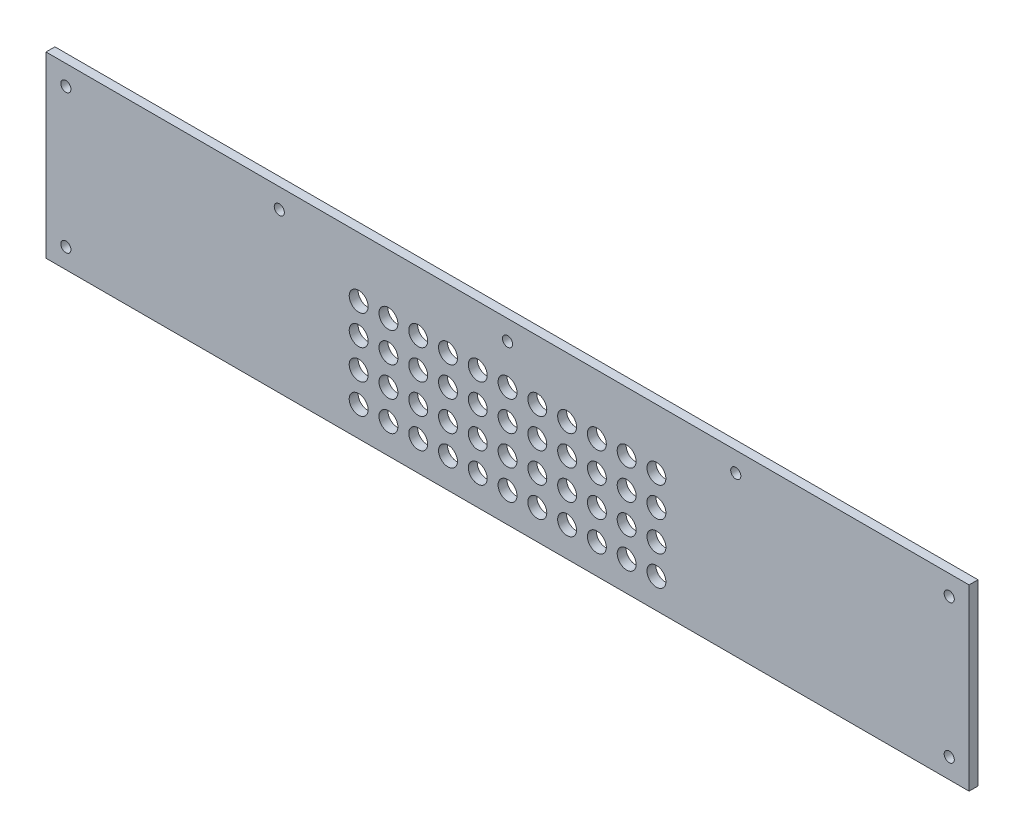
from build123d import *

# Parameters (mm, degrees)
SKETCH1_W           = 465
SKETCH1_H           = 90
SKETCH1_R           = 2.55
BOSS_EXTRUDE1_DEPTH = 2.2479
SKETCH2_R           = 4.7625
CUT_EXTRUDE1_DEPTH  = 4.4958


with BuildPart() as part:
    # Sketch1 → Boss-Extrude1 (new body, symmetric)
    with BuildSketch(Plane.XY):
        Rectangle(SKETCH1_W, SKETCH1_H)
        with Locations((-222.5, 35)):
            Circle(SKETCH1_R, mode=Mode.SUBTRACT)
        with Locations((-222.5, -35)):
            Circle(SKETCH1_R, mode=Mode.SUBTRACT)
        with Locations((0, 35)):
            Circle(SKETCH1_R, mode=Mode.SUBTRACT)
        with Locations((-114.975, 35)):
            Circle(SKETCH1_R, mode=Mode.SUBTRACT)
        with Locations((222.5, -35)):
            Circle(SKETCH1_R, mode=Mode.SUBTRACT)
        with Locations((222.5, 35)):
            Circle(SKETCH1_R, mode=Mode.SUBTRACT)
        with Locations((114.975, 35)):
            Circle(SKETCH1_R, mode=Mode.SUBTRACT)
    extrude(amount=BOSS_EXTRUDE1_DEPTH, both=True)

    # Sketch2 → Cut-Extrude1 (cut)
    with BuildSketch(Plane.XY.offset(2.2479)):
        with Locations((0, 15)):
            Circle(SKETCH2_R)
        with Locations((15, 15)):
            Circle(SKETCH2_R)
        with Locations((30, 15)):
            Circle(SKETCH2_R)
        with Locations((45, 15)):
            Circle(SKETCH2_R)
        with Locations((60, 15)):
            Circle(SKETCH2_R)
        with Locations((75, 15)):
            Circle(SKETCH2_R)
        with Locations((15, 0)):
            Circle(SKETCH2_R)
        with Locations((30, 0)):
            Circle(SKETCH2_R)
        with Locations((45, 0)):
            Circle(SKETCH2_R)
        with Locations((60, 0)):
            Circle(SKETCH2_R)
        with Locations((75, 0)):
            Circle(SKETCH2_R)
        with Locations((15, -15)):
            Circle(SKETCH2_R)
        with Locations((30, -15)):
            Circle(SKETCH2_R)
        with Locations((45, -15)):
            Circle(SKETCH2_R)
        with Locations((60, -15)):
            Circle(SKETCH2_R)
        with Locations((75, -15)):
            Circle(SKETCH2_R)
        with Locations((15, -30)):
            Circle(SKETCH2_R)
        with Locations((30, -30)):
            Circle(SKETCH2_R)
        with Locations((45, -30)):
            Circle(SKETCH2_R)
        with Locations((60, -30)):
            Circle(SKETCH2_R)
        with Locations((75, -30)):
            Circle(SKETCH2_R)
        Circle(SKETCH2_R)
        with Locations((0, -15)):
            Circle(SKETCH2_R)
        with Locations((0, -30)):
            Circle(SKETCH2_R)
        with Locations((-75, -30)):
            Circle(SKETCH2_R)
        with Locations((-60, -30)):
            Circle(SKETCH2_R)
        with Locations((-45, -30)):
            Circle(SKETCH2_R)
        with Locations((-30, -30)):
            Circle(SKETCH2_R)
        with Locations((-15, -30)):
            Circle(SKETCH2_R)
        with Locations((-75, -15)):
            Circle(SKETCH2_R)
        with Locations((-60, -15)):
            Circle(SKETCH2_R)
        with Locations((-45, -15)):
            Circle(SKETCH2_R)
        with Locations((-30, -15)):
            Circle(SKETCH2_R)
        with Locations((-15, -15)):
            Circle(SKETCH2_R)
        with Locations((-75, 0)):
            Circle(SKETCH2_R)
        with Locations((-60, 0)):
            Circle(SKETCH2_R)
        with Locations((-45, 0)):
            Circle(SKETCH2_R)
        with Locations((-30, 0)):
            Circle(SKETCH2_R)
        with Locations((-15, 0)):
            Circle(SKETCH2_R)
        with Locations((-75, 15)):
            Circle(SKETCH2_R)
        with Locations((-60, 15)):
            Circle(SKETCH2_R)
        with Locations((-45, 15)):
            Circle(SKETCH2_R)
        with Locations((-30, 15)):
            Circle(SKETCH2_R)
        with Locations((-15, 15)):
            Circle(SKETCH2_R)
    extrude(amount=-CUT_EXTRUDE1_DEPTH, mode=Mode.SUBTRACT)


solid = part.part
